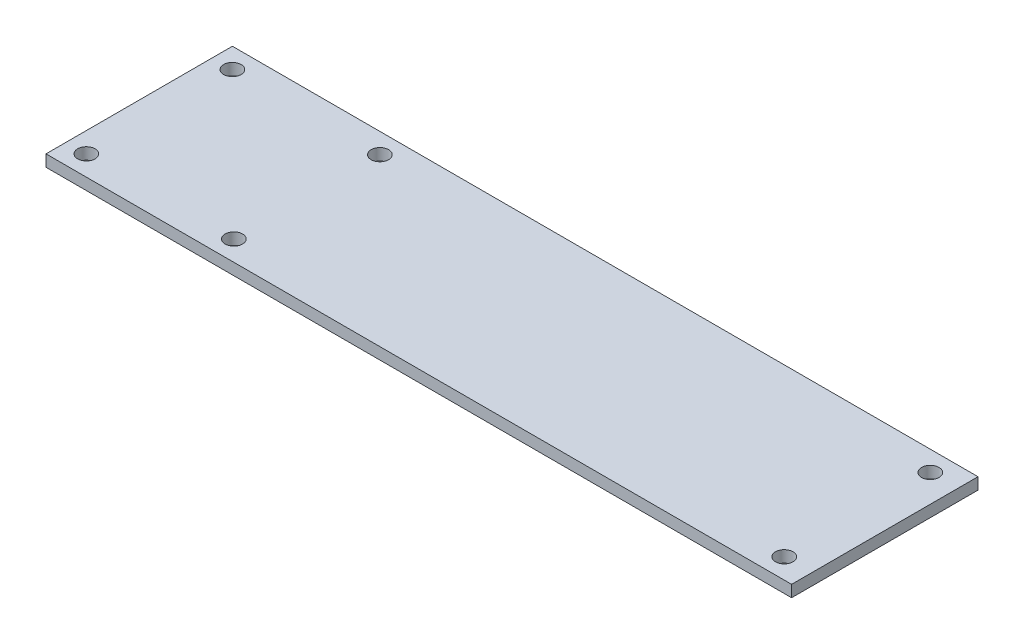
from build123d import *

# Parameters (mm, degrees)
CROQUIS2_W              = 406.4
CROQUIS2_H              = 101.6
SALIENTE_EXTRUIR1_DEPTH = 6.35
CROQUIS4_R              = 4.7625
CORTAR_EXTRUIR2_DEPTH   = 6.35


with BuildPart() as part:
    # Croquis2 → Saliente-Extruir1 (new body)
    with BuildSketch(Plane(origin=(0, 0, 0), x_dir=(1, 0, 0), z_dir=(0, 1, 0))):
        Rectangle(CROQUIS2_W, CROQUIS2_H)
    extrude(amount=SALIENTE_EXTRUIR1_DEPTH)

    # Croquis4 → Cortar-Extruir2 (cut)
    with BuildSketch(Plane(origin=(0, 6.35, 0), x_dir=(1, 0, 0), z_dir=(0, 1, 0))):
        with Locations((-192.2, 39.8)):
            Circle(CROQUIS4_R)
        with Locations((188.2, 39.8)):
            Circle(CROQUIS4_R)
        with Locations((188.2, -39.8)):
            Circle(CROQUIS4_R)
        with Locations((-192.2, -39.8)):
            Circle(CROQUIS4_R)
        with Locations((-111.81, 39.8)):
            Circle(CROQUIS4_R)
        with Locations((-111.81, -39.8)):
            Circle(CROQUIS4_R)
    extrude(amount=-CORTAR_EXTRUIR2_DEPTH, mode=Mode.SUBTRACT)


solid = part.part
